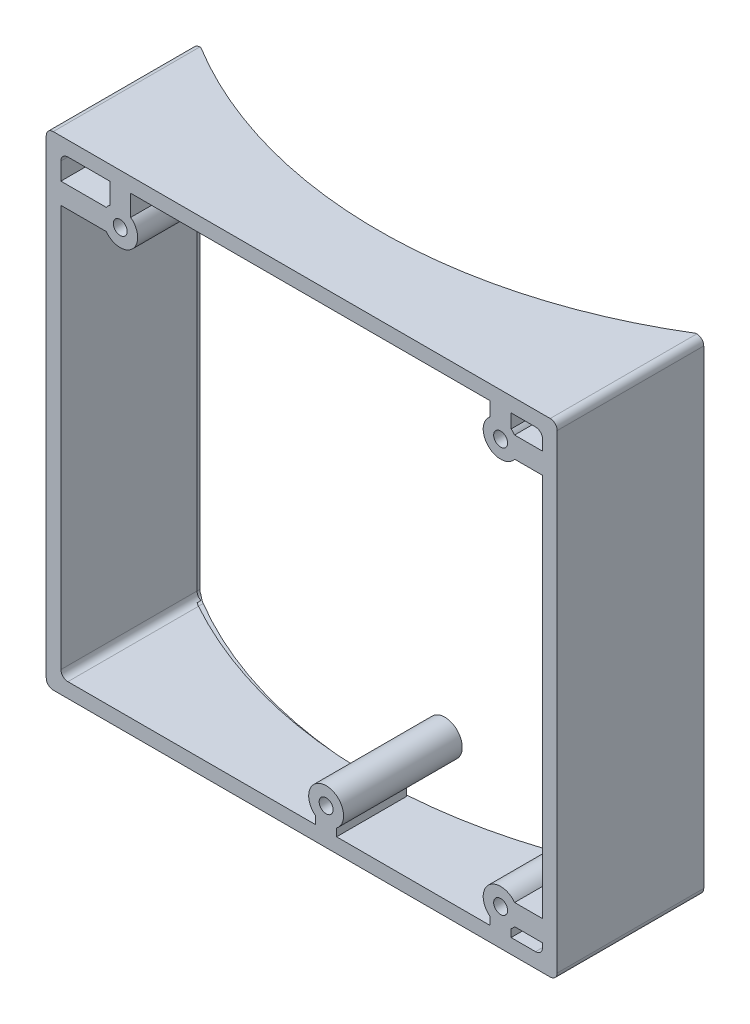
from build123d import *

# Parameters (mm, degrees)
SKIZZE1_R                         = 2.5
SKIZZE1_R_2                       = 1
AUFSATZ_LINEAR_AUSTRAGEN1_DEPTH   = 17
AUFSATZ_LINEAR_AUSTRAGEN1_2_DEPTH = 17
AUFSATZ_LINEAR_AUSTRAGEN1_3_DEPTH = 17
AUFSATZ_LINEAR_AUSTRAGEN1_4_DEPTH = 17
SKIZZE1_3_W                       = 73.2
SKIZZE1_3_H                       = 69.3
SKIZZE1_3_W_2                     = 71.2
SKIZZE1_3_H_2                     = 67.3
AUFSATZ_LINEAR_AUSTRAGEN2_DEPTH   = 21
SKIZZE1_4_W                       = 71.2
SKIZZE1_4_H                       = 67.3
AUFSATZ_LINEAR_AUSTRAGEN3_DEPTH   = 19.5
SCHNITT_LINEAR_AUSTRAGEN1_DEPTH   = 2.1
SCHNITT_LINEAR_START              = -1
SCHNITT_LINEAR_AUSTRAGEN4_DEPTH   = 1.2
SCHNITT_LINEAR_START_2            = -66.9
SCHNITT_LINEAR_AUSTRAGEN6_DEPTH   = 1.4
AUFSATZ_LINEAR_AUSTRAGEN4_DEPTH   = 10
SCHNITT_LINEAR_AUSTRAGEN7_DEPTH   = 10
VERRUNDUNG1_R                     = 1
VERRUNDUNG2_R                     = 1


with BuildPart() as part:
    # Skizze1 → Aufsatz-Linear austragen1 (new body)
    with BuildSketch(Plane.XY):
        with Locations((38, 3.1)):
            Circle(SKIZZE1_R)
        with Locations((38, 3.1)):
            Circle(SKIZZE1_R_2, mode=Mode.SUBTRACT)
    extrude(amount=-AUFSATZ_LINEAR_AUSTRAGEN1_DEPTH)



with BuildPart() as body_2:
    # Skizze1 → Aufsatz-Linear austragen1 2 (new body)
    with BuildSketch(Plane.XY):
        with Locations((8.5, 60.1)):
            Circle(SKIZZE1_R)
        with Locations((8.5, 60.1)):
            Circle(SKIZZE1_R_2, mode=Mode.SUBTRACT)
    extrude(amount=-AUFSATZ_LINEAR_AUSTRAGEN1_2_DEPTH)


with BuildPart() as body_3:
    # Skizze1 → Aufsatz-Linear austragen1 3 (new body)
    with BuildSketch(Plane.XY):
        with Locations((63, 3.1)):
            Circle(SKIZZE1_R)
        with Locations((63, 3.1)):
            Circle(SKIZZE1_R_2, mode=Mode.SUBTRACT)
    extrude(amount=-AUFSATZ_LINEAR_AUSTRAGEN1_3_DEPTH)


with BuildPart() as body_4:
    # Skizze1 → Aufsatz-Linear austragen1 4 (new body)
    with BuildSketch(Plane.XY):
        with Locations((63, 61.1)):
            Circle(SKIZZE1_R)
        with Locations((63, 61.1)):
            Circle(SKIZZE1_R_2, mode=Mode.SUBTRACT)
    extrude(amount=-AUFSATZ_LINEAR_AUSTRAGEN1_4_DEPTH)


with BuildPart() as body_5:
    # Skizze1_3 → Aufsatz-Linear austragen2 (new body)
    with BuildSketch(Plane.XY):
        with Locations((34.5, 32.55)):
            Rectangle(SKIZZE1_3_W, SKIZZE1_3_H)
        with Locations((34.5, 32.55)):
            Rectangle(SKIZZE1_3_W_2, SKIZZE1_3_H_2, mode=Mode.SUBTRACT)
    extrude(amount=-AUFSATZ_LINEAR_AUSTRAGEN2_DEPTH)

    # Skizze1_4 → Aufsatz-Linear austragen3 (add)
    with BuildSketch(Plane.XY):
        with Locations((34.5, 32.55)):
            Rectangle(SKIZZE1_4_W, SKIZZE1_4_H)
        Polygon((36.5, 0), (0, 0), (0, 58.6), (0, 60.1), (0, 61.6), (0, 65.1), (7, 65.1), (8.5, 65.1), (10, 65.1), (61.5, 65.1), (63, 65.1), (64.5, 65.1), (69, 65.1), (69, 62.6), (69, 61.1), (69, 59.6), (69, 4.6), (69, 3.1), (69, 1.6), (69, 0), (64.5, 0), (63, 0), (61.5, 0), (39.5, 0), (38, 0), align=None, mode=Mode.SUBTRACT)
    extrude(amount=-AUFSATZ_LINEAR_AUSTRAGEN3_DEPTH)

    # Skizze2 → Schnitt-Linear austragen1 (cut)
    with BuildSketch(Plane(origin=(0, -2.1, 0), x_dir=(-1, 0, 0), z_dir=(0, -1, 0))):
        with BuildLine():
            ThreePointArc((-69.94600721, 21), (-34.5, 11.026332841), (0.94600721, 21))
            Line((0.94600721, 21), (-69.94600721, 21))
        make_face()
    extrude(amount=-SCHNITT_LINEAR_AUSTRAGEN1_DEPTH, mode=Mode.SUBTRACT)

    # Skizze2_6 → Schnitt-Linear austragen4 (cut)
    with BuildSketch(Plane(origin=(0, -2.1, 0), x_dir=(-1, 0, 0), z_dir=(0, -1, 0)).offset(SCHNITT_LINEAR_START)):
        with BuildLine():
            Line((0.94600721, 19.831196274), (0.94600721, 21))
            ThreePointArc((0.94600721, 21), (-34.5, 11.026332841), (-69.94600721, 21))
            Line((-69.94600721, 21), (-69.94600721, 19.831196274))
            ThreePointArc((-69.94600721, 19.831196274), (-34.5, 10.026332841), (0.94600721, 19.831196274))
        make_face()
    extrude(amount=-SCHNITT_LINEAR_AUSTRAGEN4_DEPTH, mode=Mode.SUBTRACT)

    # Skizze2_14 → Schnitt-Linear austragen6 (cut)
    with BuildSketch(Plane(origin=(0, -2.1, 0), x_dir=(-1, 0, 0), z_dir=(0, -1, 0)).offset(SCHNITT_LINEAR_START_2)):
        with BuildLine():
            Line((0.94600721, 19.831196274), (0.94600721, 21))
            ThreePointArc((0.94600721, 21), (-34.5, 11.026332841), (-69.94600721, 21))
            Line((-69.94600721, 21), (-69.94600721, 19.831196274))
            ThreePointArc((-69.94600721, 19.831196274), (-34.5, 10.026332841), (0.94600721, 19.831196274))
        make_face()
    extrude(amount=-SCHNITT_LINEAR_AUSTRAGEN6_DEPTH, mode=Mode.SUBTRACT)


with BuildPart() as part_1:
    add(part.part)

    add(body_2.part)  # Aufsatz-Linear austragen4 merges body 2

    add(body_3.part)  # Aufsatz-Linear austragen4 merges body 3

    add(body_4.part)  # Aufsatz-Linear austragen4 merges body 4

    add(body_5.part)  # Aufsatz-Linear austragen4 merges body 5
    # Skizze1_5 → Aufsatz-Linear austragen4 (add)
    with BuildSketch(Plane.XY):
        with BuildLine():
            Line((36.5, 1.1), (36.5, 0))
            Line((36.5, 0), (39.5, 0))
            Line((39.5, 0), (39.5, 1.1))
            ThreePointArc((39.5, 1.1), (38, 0.6), (36.5, 1.1))
        make_face()
        with BuildLine():
            Line((0, 58.6), (6.5, 58.6))
            ThreePointArc((6.5, 58.6), (6, 60.1), (6.5, 61.6))
            Line((6.5, 61.6), (0, 61.6))
            Line((0, 61.6), (0, 58.6))
        make_face()
        with BuildLine():
            Line((61.5, 1.1), (61.5, 0))
            Line((61.5, 0), (64.5, 0))
            Line((64.5, 0), (64.5, 1.1))
            ThreePointArc((64.5, 1.1), (63, 0.6), (61.5, 1.1))
        make_face()
        with BuildLine():
            Line((10, 62.1), (10, 65.1))
            Line((10, 65.1), (7, 65.1))
            Line((7, 65.1), (7, 62.1))
            ThreePointArc((7, 62.1), (8.5, 62.6), (10, 62.1))
        make_face()
        with BuildLine():
            Line((69, 4.6), (65, 4.6))
            ThreePointArc((65, 4.6), (65.5, 3.1), (65, 1.6))
            Line((65, 1.6), (69, 1.6))
            Line((69, 1.6), (69, 4.6))
        make_face()
        with BuildLine():
            Line((61.5, 65.1), (61.5, 63.1))
            ThreePointArc((61.5, 63.1), (63, 63.6), (64.5, 63.1))
            Line((64.5, 63.1), (64.5, 65.1))
            Line((64.5, 65.1), (61.5, 65.1))
        make_face()
        with BuildLine():
            Line((65, 59.6), (69, 59.6))
            Line((69, 59.6), (69, 62.6))
            Line((69, 62.6), (65, 62.6))
            ThreePointArc((65, 62.6), (65.5, 61.1), (65, 59.6))
        make_face()
    extrude(amount=-AUFSATZ_LINEAR_AUSTRAGEN4_DEPTH)

    # Skizze2_15 → Schnitt-Linear austragen7 (cut)
    with BuildSketch(Plane(origin=(0, -2.1, 0), x_dir=(-1, 0, 0), z_dir=(0, -1, 0)).offset(SCHNITT_LINEAR_START_2)):
        with BuildLine():
            ThreePointArc((-69.94600721, 21), (-34.5, 11.026332841), (0.94600721, 21))
            Line((0.94600721, 21), (-69.94600721, 21))
        make_face()
    extrude(amount=-SCHNITT_LINEAR_AUSTRAGEN7_DEPTH, mode=Mode.SUBTRACT)

    # Verrundung1
    verrundung1_edges = [part_1.edges().sort_by_distance(p)[0] for p in [
        (0, 65.1, -9.63732781),
        (69, 65.1, -9.63732781),
        (69, 0, -9.63732781),
        (0, 0, -9.63732781),
        (-2.1, -2.1, -10.5),
        (71.1, -2.1, -10.5),
        (71.1, 67.2, -10.5),
        (-2.1, 67.2, -10.5),
    ]]
    fillet(verrundung1_edges, radius=VERRUNDUNG1_R)

    # Verrundung2
    verrundung2_edges = [part_1.edges().sort_by_distance(p)[0] for p in [
        (70.1, 66.2, -20.25),
        (70.1, -1.1, -20.25),
        (-1.1, -1.1, -20.25),
        (-1.1, 66.2, -20.25),
    ]]
    fillet(verrundung2_edges, radius=VERRUNDUNG2_R)


solid = part_1.part
